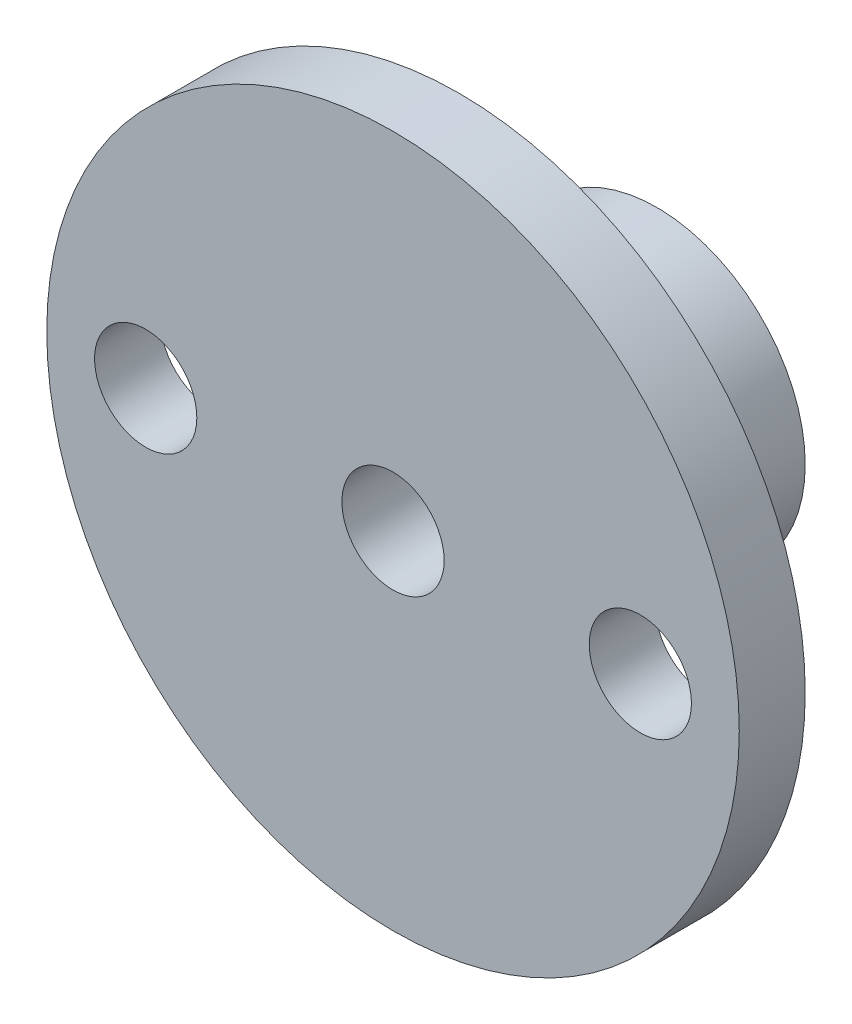
from build123d import *

# Parameters (mm, degrees)
ESQUISSE1_R             = 4.5
EXTRUSION1_DEPTH        = 6
ESQUISSE2_R             = 10.5
EXTRUSION2_DEPTH        = 2
ESQUISSE3_R             = 1.55
ENL_V_MAT_EXTRU_1_DEPTH = 9
ESQUISSE4_R             = 1.55
ENL_V_MAT_EXTRU_2_DEPTH = 9
ESQUISSE5_R             = 1.5
ENL_V_MAT_EXTRU_3_DEPTH = 10


with BuildPart() as part:
    # Esquisse1 → Extrusion1 (new body)
    with BuildSketch(Plane.XY):
        Circle(ESQUISSE1_R)
    extrude(amount=EXTRUSION1_DEPTH)

    # Esquisse2 → Extrusion2 (add)
    with BuildSketch(Plane.XY.offset(6)):
        Circle(ESQUISSE2_R)
    extrude(amount=EXTRUSION2_DEPTH)

    # Esquisse3 → Enl_v. mat.-Extru.1 (cut, through all)
    with BuildSketch(Plane.XY.offset(8)):
        Circle(ESQUISSE3_R)
    extrude(amount=-ENL_V_MAT_EXTRU_1_DEPTH, mode=Mode.SUBTRACT)

    # Esquisse4 → Enl_v. mat.-Extru.2 (cut, through all)
    with BuildSketch(Plane.XY.offset(8)):
        with Locations((-7.5, 0)):
            Circle(ESQUISSE4_R)
        with Locations((7.5, 0)):
            Circle(ESQUISSE4_R)
    extrude(amount=-ENL_V_MAT_EXTRU_2_DEPTH, mode=Mode.SUBTRACT)

    # Esquisse5 → Enl_v. mat.-Extru.3 (cut)
    with BuildSketch(Plane(origin=(0, 0, 0), x_dir=(1, 0, 0), z_dir=(0, 1, 0))):
        with Locations(Location((0, -3, 0), (0, 0, 270))):  # turned: the seam where the file's is
            Circle(ESQUISSE5_R)
    extrude(amount=-ENL_V_MAT_EXTRU_3_DEPTH, mode=Mode.SUBTRACT)


solid = part.part
